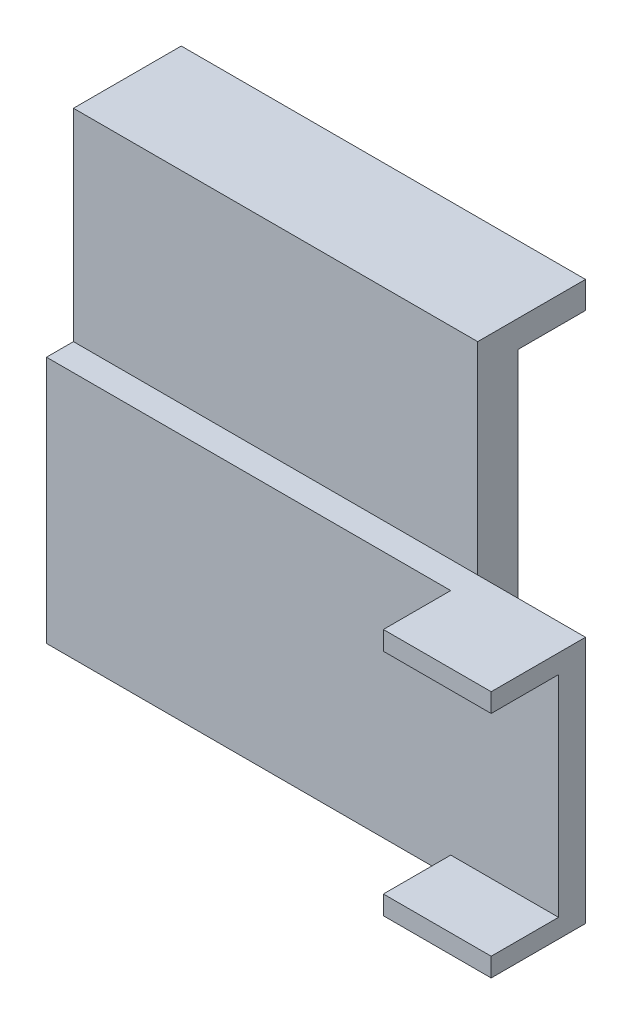
from build123d import *

# Parameters (mm, degrees)
SKETCH2_W           = 50.8
SKETCH2_H           = 23.368
BOSS_EXTRUDE1_DEPTH = 2.54
SKETCH3_W           = 12.7
SKETCH3_H           = 1.778
BOSS_EXTRUDE2_DEPTH = 6.35
SKETCH4_W           = 2.54
SKETCH4_H           = 8.89
CUT_EXTRUDE1_DEPTH  = 24.368
BOSS_EXTRUDE3_DEPTH = 3.81
SKETCH10_W          = 38.1
SKETCH10_H          = 2.54
BOSS_EXTRUDE6_DEPTH = 6.35
SCALE1_SCALE        = 1.02


with BuildPart() as part:
    # Sketch2 → Boss-Extrude1 (new body)
    with BuildSketch(Plane.XY):
        Rectangle(SKETCH2_W, SKETCH2_H)
    extrude(amount=BOSS_EXTRUDE1_DEPTH)

    # Sketch3 → Boss-Extrude2 (add)
    with BuildSketch(Plane.XY.offset(2.54)):
        with Locations((19.05, 10.795)):
            Rectangle(SKETCH3_W, SKETCH3_H)
        with Locations((19.05, -10.795)):
            Rectangle(SKETCH3_W, SKETCH3_H)
    extrude(amount=BOSS_EXTRUDE2_DEPTH)

    # Sketch4 → Cut-Extrude1 (cut, through all)
    with BuildSketch(Plane(origin=(0, 11.684, 0), x_dir=(1, 0, 0), z_dir=(0, 1, 0))):
        with Locations((24.13, -4.445)):
            Rectangle(SKETCH4_W, SKETCH4_H)
    extrude(amount=-CUT_EXTRUDE1_DEPTH, mode=Mode.SUBTRACT)

    # Sketch5 → Boss-Extrude3 (add)
    with BuildSketch(Plane(origin=(0, 0, 0), x_dir=(-1, 0, 0), z_dir=(0, 0, -1))):
        Polygon((25.4, 11.684), (25.4, -11.684), (-12.7, -11.684), (-12.7, 11.684), (-12.7, 30.734), (25.4, 30.734), align=None)
    extrude(amount=BOSS_EXTRUDE3_DEPTH)

    # Sketch10 → Boss-Extrude6 (add)
    with BuildSketch(Plane(origin=(0, 0, -3.81), x_dir=(-1, 0, 0), z_dir=(0, 0, -1))):
        with Locations((6.35, 29.464)):
            Rectangle(SKETCH10_W, SKETCH10_H)
    extrude(amount=BOSS_EXTRUDE6_DEPTH)


with BuildPart() as part_1:
    # Scale1: scaled about (-4.313949838, 7.779949755, -1.122390582)
    add(part.part.scale(SCALE1_SCALE).moved(Location((0.086278997, -0.155598995, 0.022447812))))


solid = part_1.part
